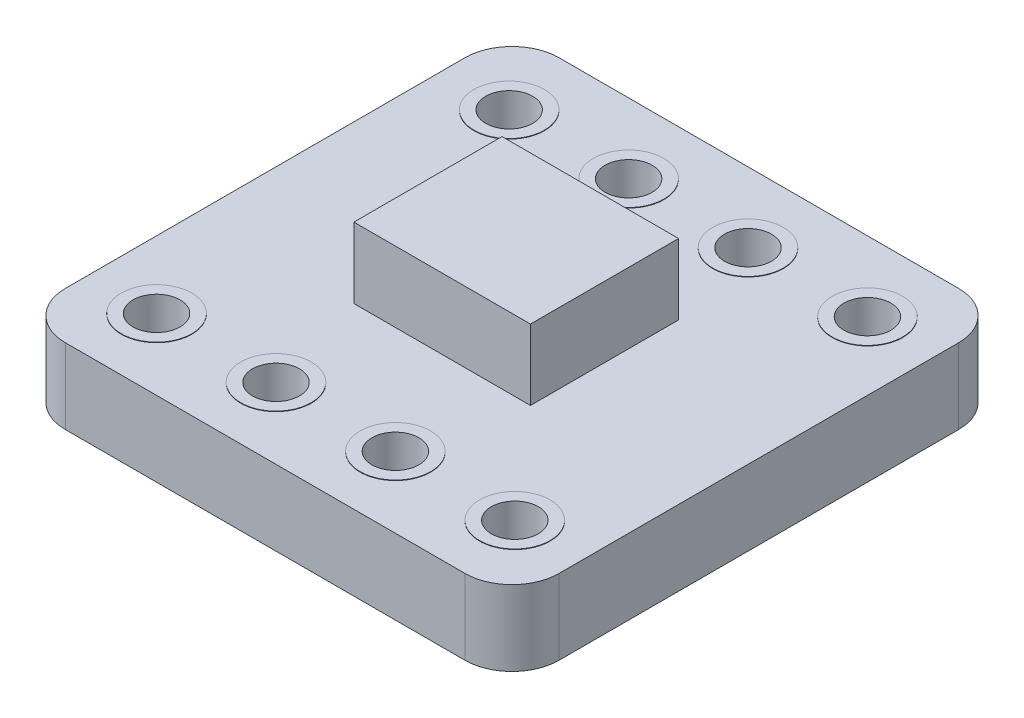
from build123d import *

# Parameters (mm, degrees)
SKETCH1_W           = 10.5
SKETCH1_H           = 10.5
BOSS_EXTRUDE1_DEPTH = 1.6
FILLET1_R           = 1
SKETCH2_R           = 0.75
SKETCH2_R_2         = 0.5
BOSS_EXTRUDE2_DEPTH = 0.01
SKETCH4_R           = 0.5
CUT_EXTRUDE1_DEPTH  = 2
SKETCH5_W           = 3.755390915
SKETCH5_H           = 3.150927308
BOSS_EXTRUDE3_DEPTH = 1.5


with BuildPart() as part:
    # Sketch1 → Boss-Extrude1 (new body)
    with BuildSketch(Plane(origin=(0, 0, 0), x_dir=(1, 0, 0), z_dir=(0, 1, 0))):
        with Locations((5.25, 5.25)):
            Rectangle(SKETCH1_W, SKETCH1_H)
    extrude(amount=BOSS_EXTRUDE1_DEPTH)

    # Fillet1
    fillet1_edges = [part.edges().sort_by_distance(p)[0] for p in [
        (0, 0.8, -10.5),
        (10.5, 0.8, -10.5),
        (10.5, 0.8, 0),
        (0, 0.8, 0),
    ]]
    fillet(fillet1_edges, radius=FILLET1_R)

    # Sketch2 → Boss-Extrude2 (add)
    with BuildSketch(Plane(origin=(0, 1.6, 0), x_dir=(1, 0, 0), z_dir=(0, 1, 0))):
        with Locations((1.44, 1.5)):
            Circle(SKETCH2_R)
        with Locations((1.44, 1.5)):
            Circle(SKETCH2_R_2, mode=Mode.SUBTRACT)
        with Locations((3.98, 1.5)):
            Circle(SKETCH2_R)
        with Locations((3.98, 1.5)):
            Circle(SKETCH2_R_2, mode=Mode.SUBTRACT)
        with Locations((6.52, 1.5)):
            Circle(SKETCH2_R)
        with Locations((6.52, 1.5)):
            Circle(SKETCH2_R_2, mode=Mode.SUBTRACT)
        with Locations((9.06, 1.5)):
            Circle(SKETCH2_R)
        with Locations((9.06, 1.5)):
            Circle(SKETCH2_R_2, mode=Mode.SUBTRACT)
        with Locations((9.06, 9)):
            Circle(SKETCH2_R)
        with Locations((9.06, 9)):
            Circle(SKETCH2_R_2, mode=Mode.SUBTRACT)
        with Locations((6.52, 9)):
            Circle(SKETCH2_R)
        with Locations((6.52, 9)):
            Circle(SKETCH2_R_2, mode=Mode.SUBTRACT)
        with Locations((3.98, 9)):
            Circle(SKETCH2_R)
        with Locations((3.98, 9)):
            Circle(SKETCH2_R_2, mode=Mode.SUBTRACT)
        with Locations((1.44, 9)):
            Circle(SKETCH2_R)
        with Locations((1.44, 9)):
            Circle(SKETCH2_R_2, mode=Mode.SUBTRACT)
    extrude(amount=BOSS_EXTRUDE2_DEPTH)

    # Sketch4 → Cut-Extrude1 (cut)
    with BuildSketch(Plane(origin=(0, 1.6, 0), x_dir=(1, 0, 0), z_dir=(0, 1, 0))):
        with Locations((9.06, 1.5)):
            Circle(SKETCH4_R)
        with Locations((6.52, 1.5)):
            Circle(SKETCH4_R)
        with Locations((3.98, 1.5)):
            Circle(SKETCH4_R)
        with Locations((1.44, 1.5)):
            Circle(SKETCH4_R)
        with Locations((1.44, 9)):
            Circle(SKETCH4_R)
        with Locations((3.98, 9)):
            Circle(SKETCH4_R)
        with Locations((6.52, 9)):
            Circle(SKETCH4_R)
        with Locations((9.06, 9)):
            Circle(SKETCH4_R)
    extrude(amount=-CUT_EXTRUDE1_DEPTH, mode=Mode.SUBTRACT)


with BuildPart() as body_2:
    # Sketch5 → Boss-Extrude3 (new body)
    with BuildSketch(Plane(origin=(0, 1.6, 0), x_dir=(1, 0, 0), z_dir=(0, 1, 0))):
        with Locations((5.224278145, 5.36574835)):
            Rectangle(SKETCH5_W, SKETCH5_H)
    extrude(amount=BOSS_EXTRUDE3_DEPTH)


solid = Compound([part.part, body_2.part])
